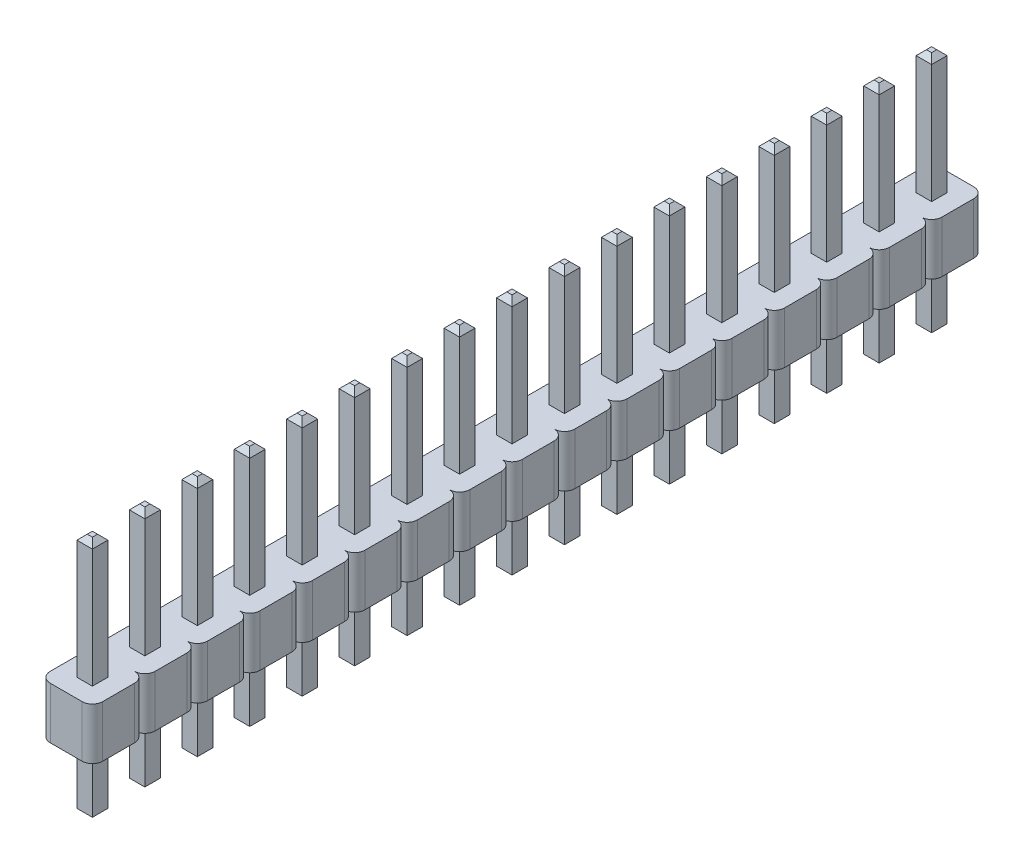
from build123d import *

# Parameters (mm, degrees)
BOSS_EXTRUDE1_DEPTH        = 2.5
BOSS_EXTRUDE2_START        = -3.25
SKETCH2_W                  = 0.75
SKETCH2_H                  = 0.75
BOSS_EXTRUDE2_DEPTH        = 11.75
CHAMFER1_SIZE              = 0.25
LPATTERN1_COUNT            = 17
LPATTERN1_PITCH            = 2.54
CHAMFER1_OF_LPATTERN1_SIZE = 0.25


with BuildPart() as part:
    # Sketch1 → Boss-Extrude1 (new body)
    with BuildSketch(Plane(origin=(0, 0, 0), x_dir=(-1, 0, 0), z_dir=(0, 1, 0))):
        with BuildLine():
            Line((-0.77, 1.27), (0.77, 1.27))
            ThreePointArc((0.77, 1.27), (1.123553391, 1.123553391), (1.27, 0.77))
            Line((1.27, 0.77), (1.27, -0.77))
            ThreePointArc((1.27, -0.77), (1.123553391, -1.123553391), (0.77, -1.27))
            Line((0.77, -1.27), (-0.77, -1.27))
            ThreePointArc((-0.77, -1.27), (-1.123553391, -1.123553391), (-1.27, -0.77))
            Line((-1.27, -0.77), (-1.27, 0.77))
            ThreePointArc((-1.27, 0.77), (-1.123553391, 1.123553391), (-0.77, 1.27))
        make_face()
    boss_extrude1 = extrude(amount=BOSS_EXTRUDE1_DEPTH)

    # Sketch2 → Boss-Extrude2 (add)
    with BuildSketch(Plane(origin=(0, 0, 0), x_dir=(-1, 0, 0), z_dir=(0, 1, 0)).offset(BOSS_EXTRUDE2_START)):
        Rectangle(SKETCH2_W, SKETCH2_H)
    boss_extrude2 = extrude(amount=BOSS_EXTRUDE2_DEPTH)

    # Chamfer1
    chamfer1_edges = [part.edges().sort_by_distance(p)[0] for p in [
        (0.375, -3.25, 0),
        (0, -3.25, 0.375),
        (-0.375, -3.25, 0),
        (0, -3.25, -0.375),
        (0.375, 8.5, 0),
        (0, 8.5, -0.375),
        (-0.375, 8.5, 0),
        (0, 8.5, 0.375),
    ]]
    chamfer(chamfer1_edges, length=CHAMFER1_SIZE)

    # LPattern1: Boss-Extrude1, Boss-Extrude2 ×17
    with Locations(*[(0, 0, -i * LPATTERN1_PITCH) for i in range(1, LPATTERN1_COUNT)]):
        add(boss_extrude1)
        add(boss_extrude2)

    # Chamfer1 of LPattern1
    chamfer1_of_lpattern1_edges = [part.edges().sort_by_distance(p)[0] for p in [
        (0.375, -3.25, -2.54),
        (0, -3.25, -2.165),
        (-0.375, -3.25, -2.54),
        (0, -3.25, -2.915),
        (0.375, 8.5, -2.54),
        (0, 8.5, -2.915),
        (-0.375, 8.5, -2.54),
        (0, 8.5, -2.165),
        (0.375, -3.25, -5.08),
        (0, -3.25, -4.705),
        (-0.375, -3.25, -5.08),
        (0, -3.25, -5.455),
        (0.375, 8.5, -5.08),
        (0, 8.5, -5.455),
        (-0.375, 8.5, -5.08),
        (0, 8.5, -4.705),
        (0.375, -3.25, -7.62),
        (0, -3.25, -7.245),
        (-0.375, -3.25, -7.62),
        (0, -3.25, -7.995),
        (0.375, 8.5, -7.62),
        (0, 8.5, -7.995),
        (-0.375, 8.5, -7.62),
        (0, 8.5, -7.245),
        (0.375, -3.25, -10.16),
        (0, -3.25, -9.785),
        (-0.375, -3.25, -10.16),
        (0, -3.25, -10.535),
        (0.375, 8.5, -10.16),
        (0, 8.5, -10.535),
        (-0.375, 8.5, -10.16),
        (0, 8.5, -9.785),
        (0.375, -3.25, -12.7),
        (0, -3.25, -12.325),
        (-0.375, -3.25, -12.7),
        (0, -3.25, -13.075),
        (0.375, 8.5, -12.7),
        (0, 8.5, -13.075),
        (-0.375, 8.5, -12.7),
        (0, 8.5, -12.325),
        (0.375, -3.25, -15.24),
        (0, -3.25, -14.865),
        (-0.375, -3.25, -15.24),
        (0, -3.25, -15.615),
        (0.375, 8.5, -15.24),
        (0, 8.5, -15.615),
        (-0.375, 8.5, -15.24),
        (0, 8.5, -14.865),
        (0.375, -3.25, -17.78),
        (0, -3.25, -17.405),
        (-0.375, -3.25, -17.78),
        (0, -3.25, -18.155),
        (0.375, 8.5, -17.78),
        (0, 8.5, -18.155),
        (-0.375, 8.5, -17.78),
        (0, 8.5, -17.405),
        (0.375, -3.25, -20.32),
        (0, -3.25, -19.945),
        (-0.375, -3.25, -20.32),
        (0, -3.25, -20.695),
        (0.375, 8.5, -20.32),
        (0, 8.5, -20.695),
        (-0.375, 8.5, -20.32),
        (0, 8.5, -19.945),
        (0.375, -3.25, -22.86),
        (0, -3.25, -22.485),
        (-0.375, -3.25, -22.86),
        (0, -3.25, -23.235),
        (0.375, 8.5, -22.86),
        (0, 8.5, -23.235),
        (-0.375, 8.5, -22.86),
        (0, 8.5, -22.485),
        (0.375, -3.25, -25.4),
        (0, -3.25, -25.025),
        (-0.375, -3.25, -25.4),
        (0, -3.25, -25.775),
        (0.375, 8.5, -25.4),
        (0, 8.5, -25.775),
        (-0.375, 8.5, -25.4),
        (0, 8.5, -25.025),
        (0.375, -3.25, -27.94),
        (0, -3.25, -27.565),
        (-0.375, -3.25, -27.94),
        (0, -3.25, -28.315),
        (0.375, 8.5, -27.94),
        (0, 8.5, -28.315),
        (-0.375, 8.5, -27.94),
        (0, 8.5, -27.565),
        (0.375, -3.25, -30.48),
        (0, -3.25, -30.105),
        (-0.375, -3.25, -30.48),
        (0, -3.25, -30.855),
        (0.375, 8.5, -30.48),
        (0, 8.5, -30.855),
        (-0.375, 8.5, -30.48),
        (0, 8.5, -30.105),
        (0.375, -3.25, -33.02),
        (0, -3.25, -32.645),
        (-0.375, -3.25, -33.02),
        (0, -3.25, -33.395),
        (0.375, 8.5, -33.02),
        (0, 8.5, -33.395),
        (-0.375, 8.5, -33.02),
        (0, 8.5, -32.645),
        (0.375, -3.25, -35.56),
        (0, -3.25, -35.185),
        (-0.375, -3.25, -35.56),
        (0, -3.25, -35.935),
        (0.375, 8.5, -35.56),
        (0, 8.5, -35.935),
        (-0.375, 8.5, -35.56),
        (0, 8.5, -35.185),
        (0.375, -3.25, -38.1),
        (0, -3.25, -37.725),
        (-0.375, -3.25, -38.1),
        (0, -3.25, -38.475),
        (0.375, 8.5, -38.1),
        (0, 8.5, -38.475),
        (-0.375, 8.5, -38.1),
        (0, 8.5, -37.725),
        (0.375, -3.25, -40.64),
        (0, -3.25, -40.265),
        (-0.375, -3.25, -40.64),
        (0, -3.25, -41.015),
        (0.375, 8.5, -40.64),
        (0, 8.5, -41.015),
        (-0.375, 8.5, -40.64),
        (0, 8.5, -40.265),
    ]]
    chamfer(chamfer1_of_lpattern1_edges, length=CHAMFER1_OF_LPATTERN1_SIZE)


solid = part.part
